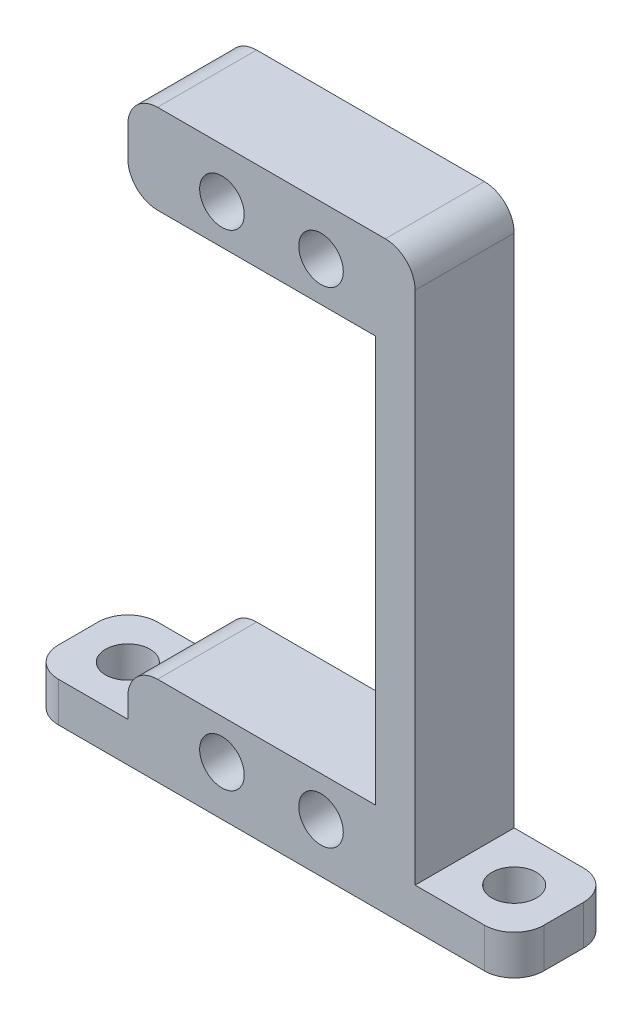
from build123d import *

# Parameters (mm, degrees)
SKETCH_1_W          = 10
SKETCH_1_H          = 4
SKETCH_1_R          = 2.25
EXTRUDE_1_DEPTH     = 10
SKETCH_2_R          = 2.25
CUT_EXTRUDE_1_DEPTH = 10
FILLET_1_R          = 3


with BuildPart() as part:
    # 草图1 → 凸台-拉伸1 (new body)
    with BuildSketch(Plane.XY):
        with Locations((-19.5, -27.5)):
            Rectangle(SKETCH_1_W, SKETCH_1_H)
        Polygon((-14.5, -20.5), (-10.5, -20.5), (10.5, -20.5), (10.5, 20.5), (-10.5, 20.5), (-14.5, 20.5), (-14.5, 29.5), (14.5, 29.5), (14.5, -29.5), (-14.5, -29.5), align=None)
        with Locations((5, 24.5)):
            Circle(SKETCH_1_R, mode=Mode.SUBTRACT)
        with Locations((-5, 24.5)):
            Circle(SKETCH_1_R, mode=Mode.SUBTRACT)
        with Locations((5, -24.5)):
            Circle(SKETCH_1_R, mode=Mode.SUBTRACT)
        with Locations((-5, -24.5)):
            Circle(SKETCH_1_R, mode=Mode.SUBTRACT)
        with Locations((19.5, -27.5)):
            Rectangle(SKETCH_1_W, SKETCH_1_H)
    extrude(amount=EXTRUDE_1_DEPTH)

    # 草图2 → 切除-拉伸1 (cut)
    with BuildSketch(Plane(origin=(0, -25.5, 0), x_dir=(1, 0, 0), z_dir=(0, 1, 0))):
        with Locations((19.5, -5)):
            Circle(SKETCH_2_R)
        with Locations((-19.5, -5)):
            Circle(SKETCH_2_R)
    extrude(amount=-CUT_EXTRUDE_1_DEPTH, mode=Mode.SUBTRACT)

    # 圆角1
    fillet_1_edges = [part.edges().sort_by_distance(p)[0] for p in [
        (-24.5, -27.5, 10),
        (24.5, -27.5, 0),
        (24.5, -27.5, 10),
        (-24.5, -27.5, 0),
        (-14.5, -20.5, 5),
        (-14.5, 20.5, 5),
        (-14.5, 29.5, 5),
        (14.5, 29.5, 5),
    ]]
    fillet(fillet_1_edges, radius=FILLET_1_R)


solid = part.part
